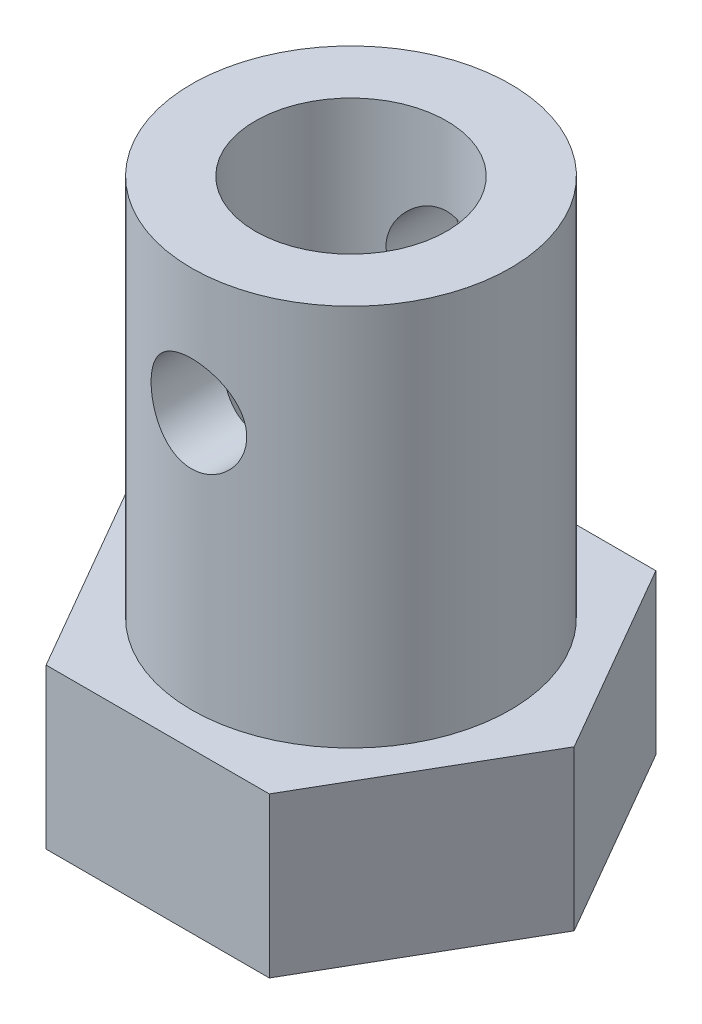
from build123d import *

# Parameters (mm, degrees)
EXTRUDE_1_DEPTH          = 5
SKETCH_3_R               = 5
EXTRUDE_2_DEPTH          = 17
SKETCH_4_R               = 3
CUT_EXTRUDE_1_DEPTH      = 17
SKETCH_6_R               = 1.5
CUT_EXTRUDE_2_DEPTH      = 5
CUT_EXTRUDE_2_DEPTH_BACK = 5


with BuildPart() as part:
    # 草图1 → 凸台-拉伸1 (new body)
    with BuildSketch(Plane(origin=(0, 0, 0), x_dir=(1, 0, 0), z_dir=(0, 1, 0))):
        Polygon((-7, 0), (-3.5, -6.062177826), (3.5, -6.062177826), (7, 0), (3.5, 6.062177826), (-3.5, 6.062177826), align=None)
    extrude(amount=EXTRUDE_1_DEPTH)

    # 草图3 → 凸台-拉伸2 (add)
    with BuildSketch(Plane(origin=(0, 0, 0), x_dir=(1, 0, 0), z_dir=(0, 1, 0))):
        Circle(SKETCH_3_R)
    extrude(amount=EXTRUDE_2_DEPTH)

    # 草图4 → 切除-拉伸1 (cut)
    with BuildSketch(Plane(origin=(0, 0, 0), x_dir=(1, 0, 0), z_dir=(0, 1, 0))):
        Circle(SKETCH_4_R)
    extrude(amount=CUT_EXTRUDE_1_DEPTH, mode=Mode.SUBTRACT)

    # 草图6 → 切除-拉伸2 (cut, two sides)
    with BuildSketch(Plane.XY) as cut_extrude_2_sk:
        with Locations((0, 13.047463788)):
            Circle(SKETCH_6_R)
    extrude(amount=CUT_EXTRUDE_2_DEPTH, mode=Mode.SUBTRACT)
    extrude(cut_extrude_2_sk.sketch, amount=-CUT_EXTRUDE_2_DEPTH_BACK, mode=Mode.SUBTRACT)


solid = part.part
